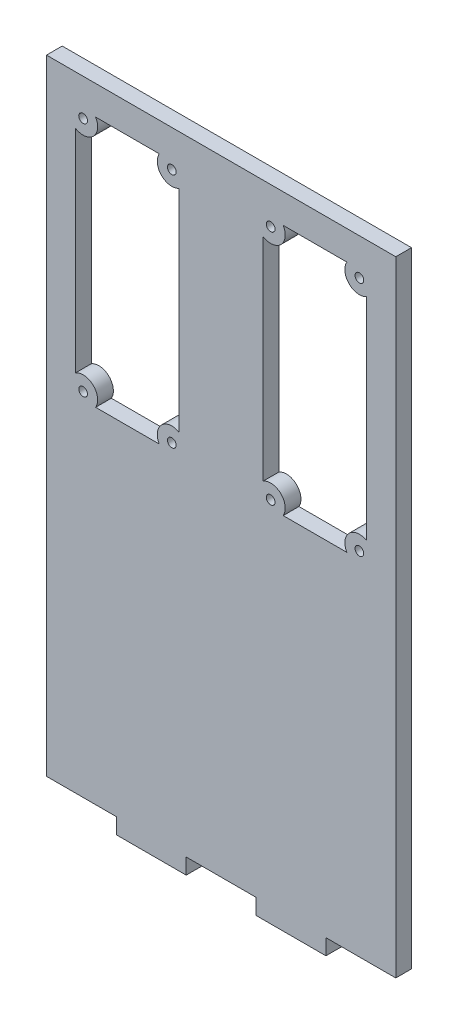
from build123d import *

# Parameters (mm, degrees)
SKETCH1_R           = 0.75
BOSS_EXTRUDE1_DEPTH = 2.7


with BuildPart() as part:
    # Sketch1 → Boss-Extrude1 (new body)
    with BuildSketch(Plane.XY):
        Polygon((-30.072121707, -52.412620775), (-30.072121707, 54.887379225), (29.927878293, 54.887379225), (29.927878293, -52.412620775), (17.927878293, -52.412620775), (17.927878293, -55.112620775), (5.927878293, -55.112620775), (5.927878293, -52.412620775), (-6.072121707, -52.412620775), (-6.072121707, -55.112620775), (-18.072121707, -55.112620775), (-18.072121707, -52.412620775), align=None)
        with Locations((-8.543810279, 48.617379225)):
            Circle(SKETCH1_R, mode=Mode.SUBTRACT)
        with Locations((-8.543810279, 7.977379225)):
            Circle(SKETCH1_R, mode=Mode.SUBTRACT)
        with Locations((-23.783810279, 7.977379225)):
            Circle(SKETCH1_R, mode=Mode.SUBTRACT)
        with Locations((-23.783810279, 48.617379225)):
            Circle(SKETCH1_R, mode=Mode.SUBTRACT)
        with Locations((23.676189721, 48.617379225)):
            Circle(SKETCH1_R, mode=Mode.SUBTRACT)
        with Locations((23.676189721, 7.977379225)):
            Circle(SKETCH1_R, mode=Mode.SUBTRACT)
        with Locations((8.436189721, 7.977379225)):
            Circle(SKETCH1_R, mode=Mode.SUBTRACT)
        with Locations((8.436189721, 48.617379225)):
            Circle(SKETCH1_R, mode=Mode.SUBTRACT)
        with BuildLine():
            Line((-10.697202951, 49.887379225), (-21.630417607, 49.887379225))
            ThreePointArc((-21.630417607, 49.887379225), (-22.023594521, 46.842093195), (-25.072121707, 46.474891496))
            Line((-25.072121707, 46.474891496), (-25.072121707, 10.119866953))
            ThreePointArc((-25.072121707, 10.119866953), (-22.023594521, 9.752665254), (-21.630417607, 6.707379225))
            Line((-21.630417607, 6.707379225), (-10.697202951, 6.707379225))
            ThreePointArc((-10.697202951, 6.707379225), (-10.319058772, 9.73763284), (-7.292121707, 10.141466958))
            Line((-7.292121707, 10.141466958), (-7.292121707, 46.453291491))
            ThreePointArc((-7.292121707, 46.453291491), (-10.319058772, 46.85712561), (-10.697202951, 49.887379225))
        make_face(mode=Mode.SUBTRACT)
        with BuildLine():
            Line((21.522797049, 49.887379225), (10.589582393, 49.887379225))
            ThreePointArc((10.589582393, 49.887379225), (10.196405479, 46.842093195), (7.147878293, 46.474891496))
            Line((7.147878293, 46.474891496), (7.147878293, 10.119866953))
            ThreePointArc((7.147878293, 10.119866953), (10.196405479, 9.752665254), (10.589582393, 6.707379225))
            Line((10.589582393, 6.707379225), (21.522797049, 6.707379225))
            ThreePointArc((21.522797049, 6.707379225), (21.900941228, 9.73763284), (24.927878293, 10.141466958))
            Line((24.927878293, 10.141466958), (24.927878293, 46.453291491))
            ThreePointArc((24.927878293, 46.453291491), (21.900941228, 46.85712561), (21.522797049, 49.887379225))
        make_face(mode=Mode.SUBTRACT)
    extrude(amount=BOSS_EXTRUDE1_DEPTH)


solid = part.part
